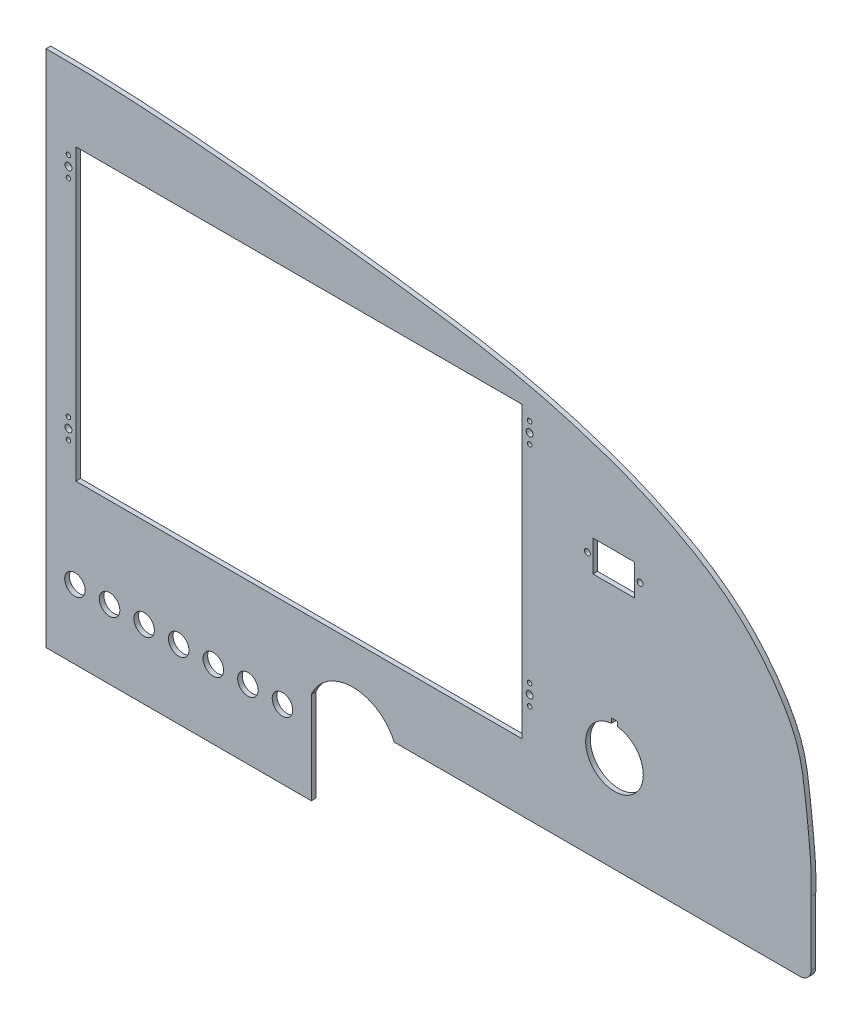
from build123d import *

# Parameters (mm, degrees)
SKETCH1_R               = 1.905
SKETCH1_R_2             = 1.2446
SKETCH1_W               = 245.872
SKETCH1_H               = 159.512
BOSS_EXTRUDE1_DEPTH     = 2.54
SKETCH2_R               = 5.6515
SKETCH2_R_2             = 15.875
SKETCH2_W               = 3.302
SKETCH2_H               = 2.54
CUT_EXTRUDE2_DEPTH      = 3.5400001
SKETCH3_R               = 1.63195
SKETCH3_W               = 22.987
SKETCH3_H               = 17.145
CUT_EXTRUDE5_DEPTH      = 3.5400001
CUT_EXTRUDE5_DEPTH_BACK = 1.0000001


with BuildPart() as part:
    # Sketch1 → Boss-Extrude1 (new body)
    with BuildSketch(Plane.XY):
        with BuildLine():
            Line((96.029310651, -57.313987504), (242.079310651, -57.313987504))
            Line((242.079310651, -57.313987504), (242.079310651, -6.513987504))
            ThreePointArc((242.079310651, -6.513987504), (264.939310651, 8.350682057), (287.799310651, -6.513987504))
            Line((287.799310651, -6.513987504), (490.999310651, -6.513987504))
            Line((490.999310651, -6.513987504), (511.285660852, -6.513987504))
            ThreePointArc((511.285660852, -6.513987504), (515.59618379, -4.728510442), (517.381660852, -0.417987504))
            Line((517.381660852, -0.417987504), (517.381660852, 34.692594504))
            add(Edge.make_bspline(
                [(515.686034075, 66.84874319), (516.918488575, 56.181556652), (517.794003636, 45.440244355), (517.381660852, 34.692594504)],
                knots=[0, 0, 0, 0, 1, 1, 1, 1], degree=3))
            add(Edge.make_bspline(
                [(96.029310651, 228.436012496), (144.926674915, 228.658270785), (203.548623262, 222.975538923), (270.563039618, 215.241730599), (301.05427316, 211.348272032), (337.403056688, 206.281684921), (371.23051068, 199.122437102), (398.574540544, 190.628647424), (416.476572896, 184.461678972), (436.853499291, 175.440168675), (458.332847863, 163.981511619), (480.853508434, 146.870738004), (498.495336111, 125.94765692), (511.792491849, 102.342414185), (513.900203367, 82.965404627), (515.116215806, 71.768257938), (515.46092989, 68.750917138), (515.686034075, 66.84874319)],
                knots=[0, 0, 0, 0, 0.254670805, 0.30696152, 0.351943382, 0.415022549, 0.498429494, 0.531879434, 0.564371393, 0.597134312, 0.648057849, 0.691030676, 0.743911859, 0.789440078, 0.832089585, 0.837987062, 0.848414849, 0.848414849, 0.848414849, 0.848414849], degree=3))
            Line((96.029310651, 228.436012496), (96.029310651, -57.313987504))
        make_face()
        with Locations((362.322574979, 178.398012496)):
            Circle(SKETCH1_R, mode=Mode.SUBTRACT)
        with Locations((108.322574979, 178.398012496)):
            Circle(SKETCH1_R, mode=Mode.SUBTRACT)
        with Locations((108.322574979, 53.430012496)):
            Circle(SKETCH1_R, mode=Mode.SUBTRACT)
        with Locations((362.322574979, 53.430012496)):
            Circle(SKETCH1_R, mode=Mode.SUBTRACT)
        with Locations((108.322574979, 183.948012496)):
            Circle(SKETCH1_R_2, mode=Mode.SUBTRACT)
        with Locations((108.322574979, 172.848012496)):
            Circle(SKETCH1_R_2, mode=Mode.SUBTRACT)
        with Locations((108.322574979, 58.980012496)):
            Circle(SKETCH1_R_2, mode=Mode.SUBTRACT)
        with Locations((108.322574979, 47.880012496)):
            Circle(SKETCH1_R_2, mode=Mode.SUBTRACT)
        with Locations((362.322574979, 183.948012496)):
            Circle(SKETCH1_R_2, mode=Mode.SUBTRACT)
        with Locations((362.322574979, 172.848012496)):
            Circle(SKETCH1_R_2, mode=Mode.SUBTRACT)
        with Locations((362.322574979, 58.980012496)):
            Circle(SKETCH1_R_2, mode=Mode.SUBTRACT)
        with Locations((362.322574979, 47.880012496)):
            Circle(SKETCH1_R_2, mode=Mode.SUBTRACT)
        with Locations((235.322574979, 110.072012496)):
            Rectangle(SKETCH1_W, SKETCH1_H, mode=Mode.SUBTRACT)
    extrude(amount=BOSS_EXTRUDE1_DEPTH)

    # Sketch2 → Cut-Extrude2 (cut, through all)
    with BuildSketch(Plane.XY.offset(2.54)):
        with Locations((111.904310651, -19.213987504)):
            Circle(SKETCH2_R)
        with Locations((130.954310651, -19.213987504)):
            Circle(SKETCH2_R)
        with Locations((150.004310651, -19.213987504)):
            Circle(SKETCH2_R)
        with Locations((169.054310651, -19.213987504)):
            Circle(SKETCH2_R)
        with Locations((188.104310651, -19.213987504)):
            Circle(SKETCH2_R)
        with Locations((207.154310651, -19.213987504)):
            Circle(SKETCH2_R)
        with Locations((226.204310651, -19.213987504)):
            Circle(SKETCH2_R)
        with Locations((409.064731107, 46.529323291)):
            Circle(SKETCH2_R_2)
        with Locations((409.064731107, 63.588237883)):
            Rectangle(SKETCH2_W, SKETCH2_H)
    extrude(amount=-CUT_EXTRUDE2_DEPTH, mode=Mode.SUBTRACT)

    # Sketch3 → Cut-Extrude5 (cut, two sides)
    with BuildSketch(Plane.XY) as cut_extrude5_sk:
        with Locations((394.154299515, 137.303914333)):
            Circle(SKETCH3_R)
        with Locations((423.161099515, 137.303914333)):
            Circle(SKETCH3_R)
        with Locations((408.657699515, 137.025719993)):
            Rectangle(SKETCH3_W, SKETCH3_H)
    extrude(amount=CUT_EXTRUDE5_DEPTH, mode=Mode.SUBTRACT)
    extrude(cut_extrude5_sk.sketch, amount=-CUT_EXTRUDE5_DEPTH_BACK, mode=Mode.SUBTRACT)


solid = part.part
